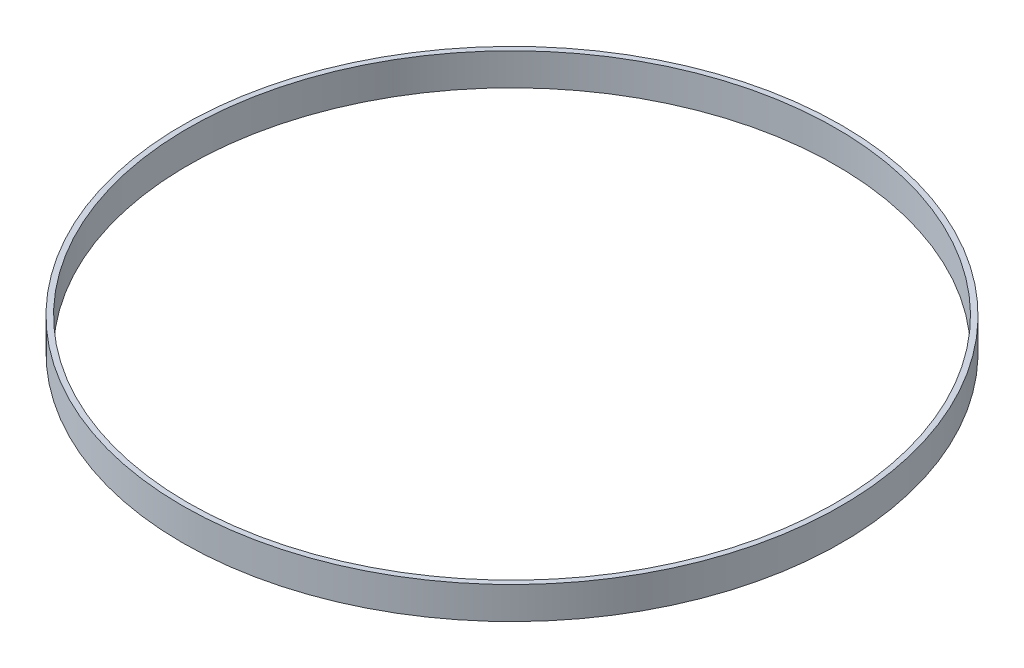
from build123d import *

# Parameters (mm, degrees)
SKETCH1_R           = 97.79
SKETCH1_R_2         = 96.2025
BOSS_EXTRUDE1_DEPTH = 9.525


with BuildPart() as part:
    # Sketch1 → Boss-Extrude1 (new body)
    with BuildSketch(Plane(origin=(0, 0, 0), x_dir=(1, 0, 0), z_dir=(0, 1, 0))):
        Circle(SKETCH1_R)
        Circle(SKETCH1_R_2, mode=Mode.SUBTRACT)
    extrude(amount=BOSS_EXTRUDE1_DEPTH)


solid = part.part
